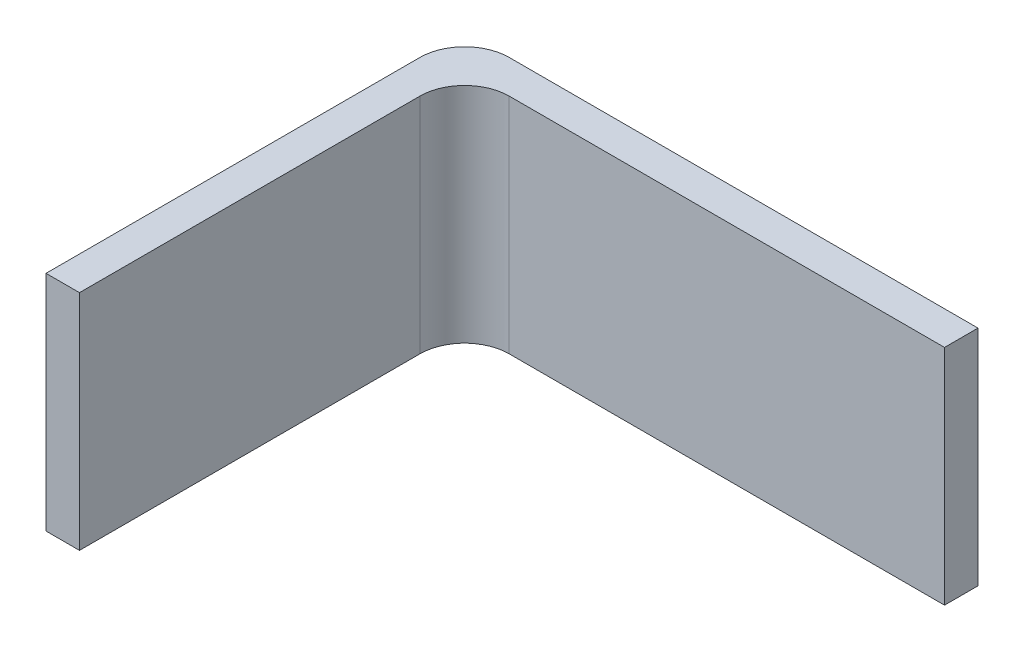
from build123d import *

# Parameters (mm, degrees)
EXTRUDE_1_DEPTH = 40


with BuildPart() as part:
    # 草图1 → 凸台-拉伸1 (new body)
    with BuildSketch(Plane(origin=(0, 0, 0), x_dir=(1, 0, 0), z_dir=(0, 1, 0))):
        with BuildLine():
            Line((0, -8), (0, -75))
            Line((0, -75), (6, -75))
            Line((6, -75), (6, -14))
            ThreePointArc((6, -14), (8.343145751, -8.343145751), (14, -6))
            Line((14, -6), (92, -6))
            Line((92, -6), (92, 0))
            Line((92, 0), (8, 0))
            ThreePointArc((8, 0), (2.343145751, -2.343145751), (0, -8))
        make_face()
    extrude(amount=EXTRUDE_1_DEPTH)


solid = part.part
